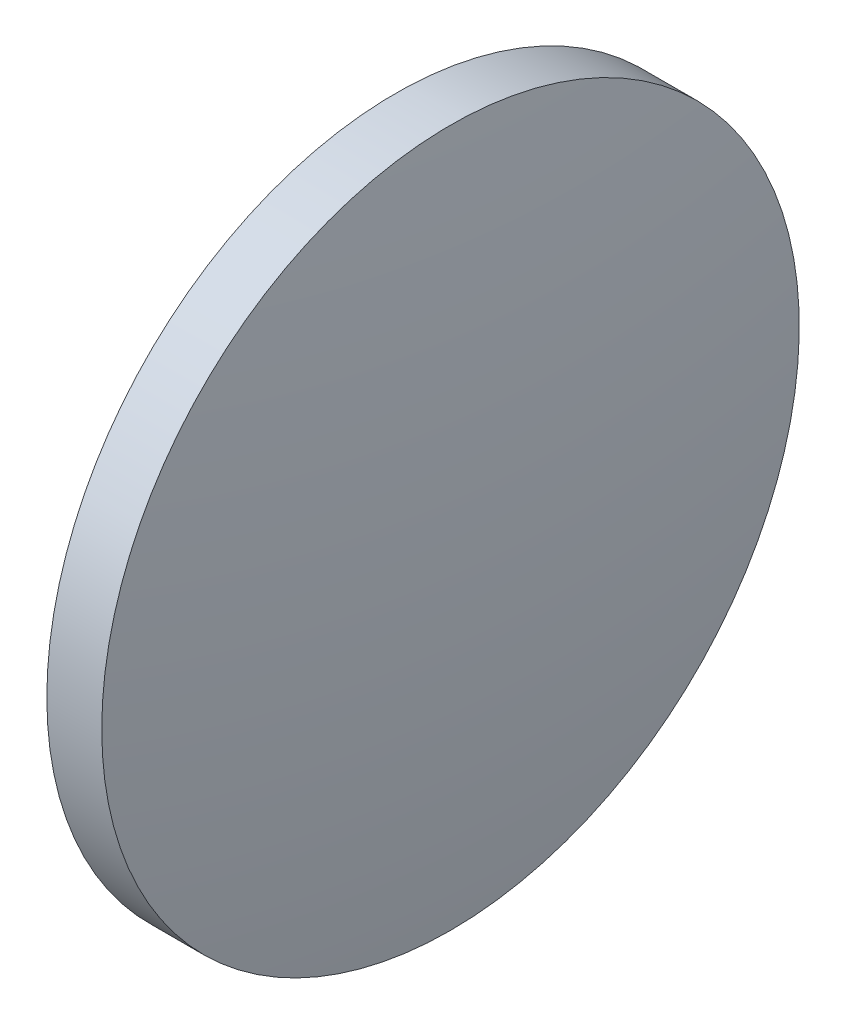
from build123d import *


with BuildPart() as part:
    # 草图1 → 旋转1 (revolve)
    with BuildSketch(Plane.XY, mode=Mode.PRIVATE) as revolve_1_sk:
        with BuildLine():
            Line((1077.35778972, 150.680985066), (1077.35778972, 163.380985066))
            Line((1077.35778972, 163.380985066), (1079.35778972, 163.380985066))
            ThreePointArc((1079.35778972, 163.380985066), (1080.032507939, 157.046909979), (1080.25778972, 150.680985066))
            Line((1080.25778972, 150.680985066), (1077.35778972, 150.680985066))
        make_face()
    revolve(revolve_1_sk.sketch.rotate(Axis((1071.619571684, 150.680985066, 0), (1, 0, 0)), 180), axis=Axis((1071.619571684, 150.680985066, 0), (1, 0, 0)))  # turned: the seam where the file's is


solid = part.part
